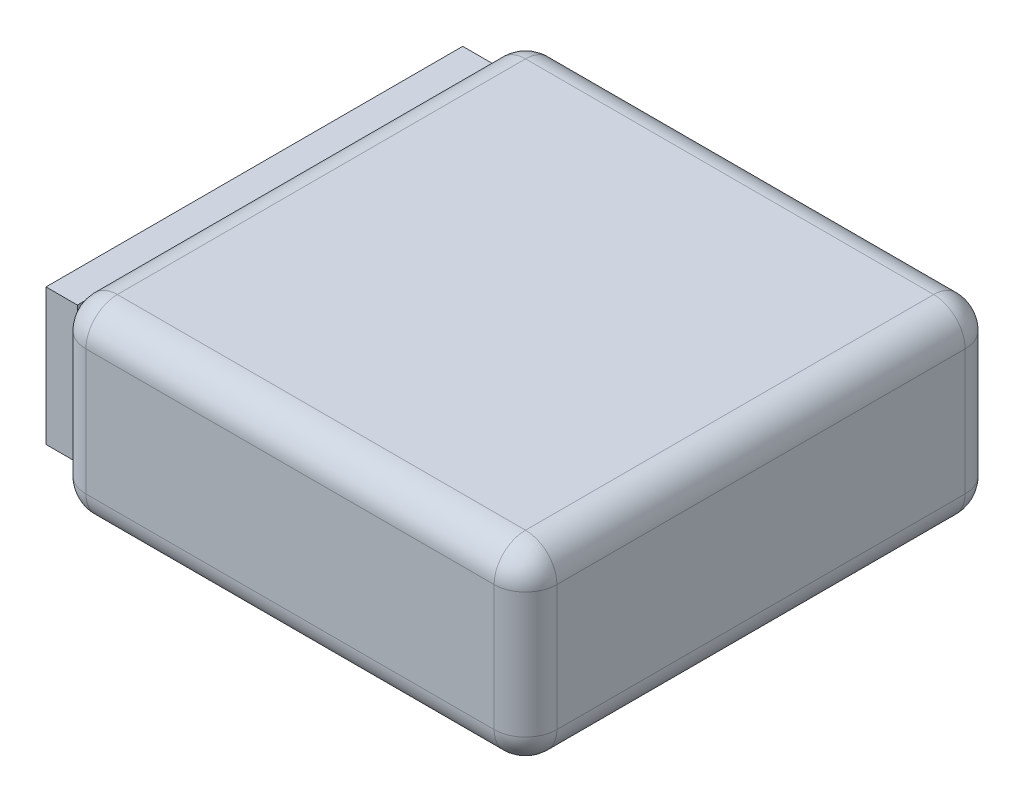
from build123d import *

# Parameters (mm, degrees)
SKETCH1_W           = 15
SKETCH1_H           = 15
BOSS_EXTRUDE1_DEPTH = 6
FILLET1_R           = 1
SKETCH2_W           = 13.272032768
SKETCH2_H           = 4.346157801
BOSS_EXTRUDE2_DEPTH = 1


with BuildPart() as part:
    # Sketch1 → Boss-Extrude1 (new body)
    with BuildSketch(Plane(origin=(0, 0, 0), x_dir=(1, 0, 0), z_dir=(0, 1, 0))):
        with Locations((-12.287002789, -4.651800626)):
            Rectangle(SKETCH1_W, SKETCH1_H)
    extrude(amount=BOSS_EXTRUDE1_DEPTH)

    # Fillet1
    fillet1_edges = [part.edges().sort_by_distance(p)[0] for p in [
        (-4.787002789, 6, 4.651800626),
        (-12.287002789, 6, -2.848199374),
        (-19.787002789, 6, 4.651800626),
        (-12.287002789, 0, -2.848199374),
        (-4.787002789, 0, 4.651800626),
        (-12.287002789, 0, 12.151800626),
        (-19.787002789, 0, 4.651800626),
        (-12.287002789, 6, 12.151800626),
        (-19.787002789, 3, -2.848199374),
        (-4.787002789, 3, -2.848199374),
        (-4.787002789, 3, 12.151800626),
        (-19.787002789, 3, 12.151800626),
    ]]
    fillet(fillet1_edges, radius=FILLET1_R)

    # Sketch2 → Boss-Extrude2 (add)
    with BuildSketch(Plane.ZY.offset(19.787002789)):
        with Locations((4.78781701, 3.173078901)):
            Rectangle(SKETCH2_W, SKETCH2_H)
    extrude(amount=BOSS_EXTRUDE2_DEPTH)


solid = part.part
